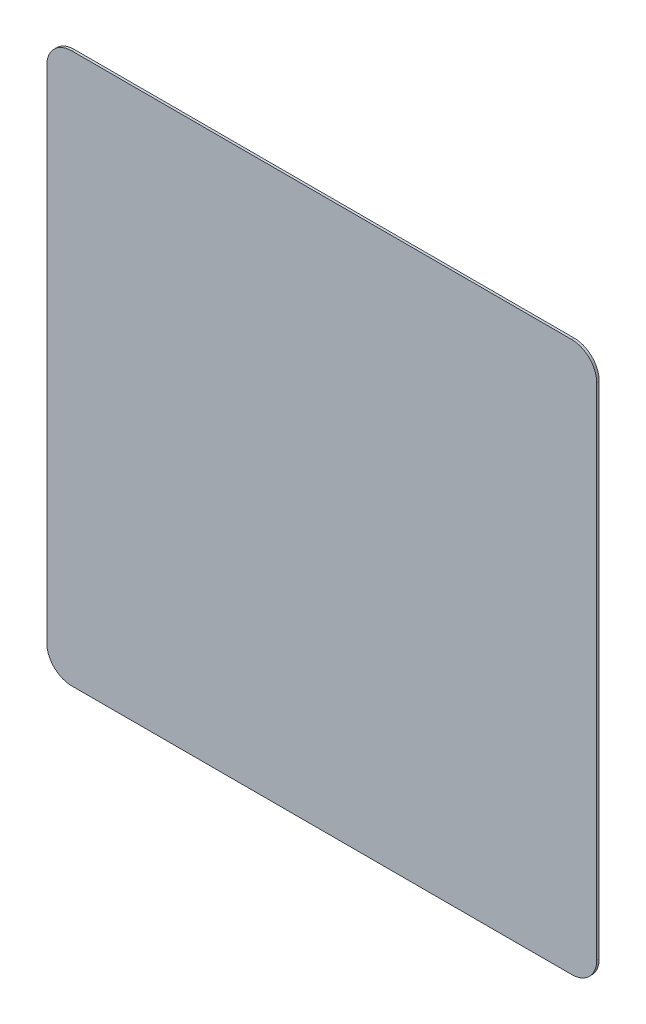
from build123d import *

# Parameters (mm, degrees)
SKETCH1_W           = 5.5
SKETCH1_H           = 5.5
BOSS_EXTRUDE1_DEPTH = 0.025
FILLET1_R           = 0.25


with BuildPart() as part:
    # Sketch1 → Boss-Extrude1 (new body)
    with BuildSketch(Plane.XY):
        Rectangle(SKETCH1_W, SKETCH1_H)
    extrude(amount=BOSS_EXTRUDE1_DEPTH)

    # Fillet1
    fillet1_edges = [part.edges().sort_by_distance(p)[0] for p in [
        (-2.75, 2.75, 0.0125),
        (2.75, 2.75, 0.0125),
        (2.75, -2.75, 0.0125),
        (-2.75, -2.75, 0.0125),
    ]]
    fillet(fillet1_edges, radius=FILLET1_R)


solid = part.part
